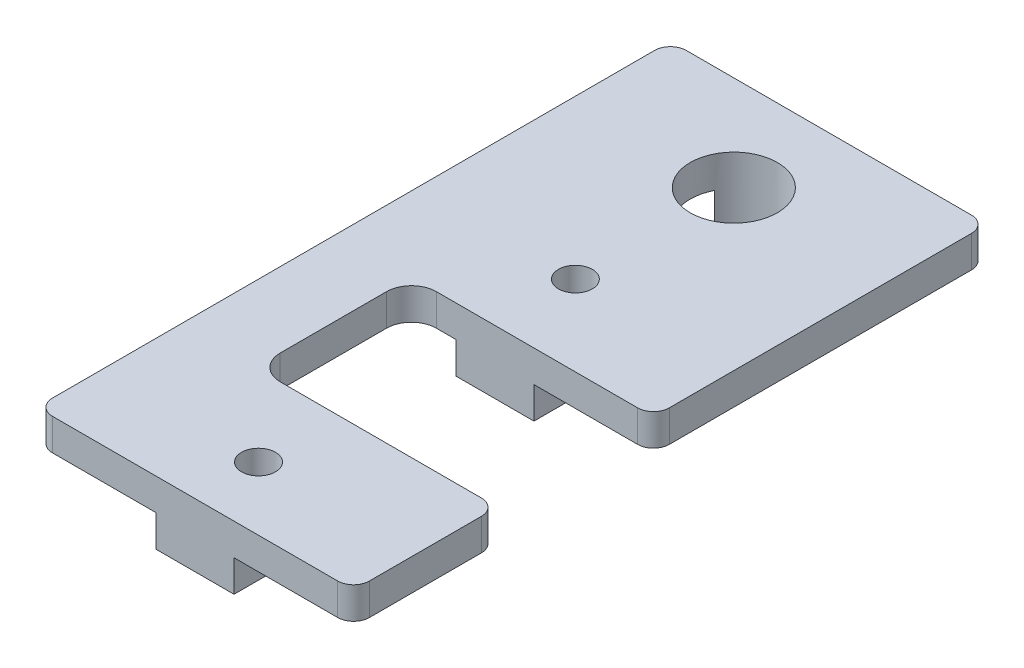
from build123d import *

# Parameters (mm, degrees)
SKETCH3_W           = 7.8
SKETCH3_H           = 3.175
SKETCH3_W_2         = 31.75
BOSS_EXTRUDE2_DEPTH = 63.5
SKETCH4_R           = 4.365625
SKETCH4_R_2         = 1.7
CUT_EXTRUDE1_DEPTH  = 7.35
FILLET1_R           = 1.5875


with BuildPart() as part:
    # Sketch3 → Boss-Extrude2 (new body)
    with BuildSketch(Plane.XY):
        with Locations((15.875, -1.5875)):
            Rectangle(SKETCH3_W, SKETCH3_H)
        with Locations((15.875, 1.5875)):
            Rectangle(SKETCH3_W_2, SKETCH3_H)
    extrude(amount=BOSS_EXTRUDE2_DEPTH)

    # Sketch4 → Cut-Extrude1 (cut, through all)
    with BuildSketch(Plane(origin=(0, 3.175, 0), x_dir=(1, 0, 0), z_dir=(0, 1, 0))):
        with BuildLine():
            Line((10, -49.1), (31.75, -49.1))
            Line((31.75, -49.1), (31.75, -33.45))
            Line((31.75, -33.45), (10, -33.45))
            ThreePointArc((10, -33.45), (8.232233047, -34.182233047), (7.5, -35.95))
            Line((7.5, -35.95), (7.5, -46.6))
            ThreePointArc((7.5, -46.6), (8.232233047, -48.367766953), (10, -49.1))
        make_face()
        with Locations((15.875, -9.525)):
            Circle(SKETCH4_R)
        with Locations((15.875, -25.4)):
            Circle(SKETCH4_R_2)
        with Locations((15.875, -57.15)):
            Circle(SKETCH4_R_2)
    extrude(amount=-CUT_EXTRUDE1_DEPTH, mode=Mode.SUBTRACT)

    # Fillet1
    fillet1_edges = [part.edges().sort_by_distance(p)[0] for p in [
        (0, 1.5875, 0),
        (31.75, 1.5875, 0),
        (31.75, 1.5875, 63.5),
        (0, 1.5875, 63.5),
        (31.75, 1.5875, 33.45),
        (31.75, 1.5875, 49.1),
    ]]
    fillet(fillet1_edges, radius=FILLET1_R)


solid = part.part
